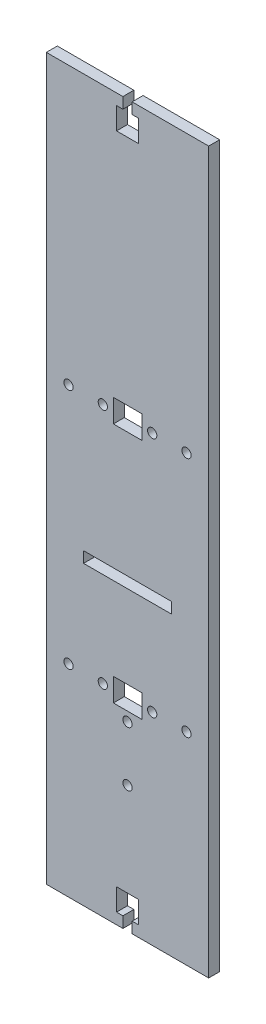
from build123d import *

# Parameters (mm, degrees)
SKETCH1_W           = 73.9
SKETCH1_H           = 328
BOSS_EXTRUDE1_DEPTH = 5
SKETCH2_R           = 2.1
CUT_EXTRUDE1_DEPTH  = 10
CUT_EXTRUDE2_DEPTH  = 10
SKETCH5_R           = 2.1
CUT_EXTRUDE3_DEPTH  = 5
SKETCH6_R           = 2.1
SKETCH6_W           = 13
SKETCH6_H           = 10.5
CUT_EXTRUDE4_DEPTH  = 180
SKETCH7_R           = 2.1
CUT_EXTRUDE5_DEPTH  = 180
SKETCH8_W           = 40
SKETCH8_H           = 5
CUT_EXTRUDE6_DEPTH  = 5


with BuildPart() as part:
    # Sketch1 → Boss-Extrude1 (new body)
    with BuildSketch(Plane.XY):
        Rectangle(SKETCH1_W, SKETCH1_H)
    extrude(amount=BOSS_EXTRUDE1_DEPTH)

    # Sketch2 → Cut-Extrude1 (cut)
    with BuildSketch(Plane.XY.offset(5)):
        with Locations((-0.000417228, -81.5)):
            Circle(SKETCH2_R)
    extrude(amount=-CUT_EXTRUDE1_DEPTH, mode=Mode.SUBTRACT)

    # Sketch3 → Cut-Extrude2 (cut)
    with BuildSketch(Plane.XY.offset(5)):
        Polygon((-2.1, -164), (-2.1, -159), (-5, -159), (-5, -149), (5, -149), (5, -159), (2.1, -159), (2.1, -164), align=None)
        Polygon((2.1, 164), (2.1, 159), (5, 159), (5, 149), (-5, 149), (-5, 159), (-2.1, 159), (-2.1, 164), align=None)
    extrude(amount=-CUT_EXTRUDE2_DEPTH, mode=Mode.SUBTRACT)

    # Sketch5 → Cut-Extrude3 (cut)
    with BuildSketch(Plane.XY.offset(5)):
        with Locations((-0.000417228, -106.5)):
            Circle(SKETCH5_R)
    extrude(amount=-CUT_EXTRUDE3_DEPTH, mode=Mode.SUBTRACT)

    # Sketch6 → Cut-Extrude4 (cut)
    with BuildSketch(Plane.XY.offset(5)):
        with Locations((-26.856574817, 38)):
            Circle(SKETCH6_R)
        with Locations((26.85574036, 38)):
            Circle(SKETCH6_R)
        with Locations((26.85574036, -72)):
            Circle(SKETCH6_R)
        with Locations((-26.856574817, -72)):
            Circle(SKETCH6_R)
        with Locations((0.059582772, 38)):
            Rectangle(SKETCH6_W, SKETCH6_H)
        with Locations((0.059582772, -72)):
            Rectangle(SKETCH6_W, SKETCH6_H)
    extrude(amount=-CUT_EXTRUDE4_DEPTH, mode=Mode.SUBTRACT)

    # Sketch7 → Cut-Extrude5 (cut)
    with BuildSketch(Plane(origin=(0, 0, 0), x_dir=(-1, 0, 0), z_dir=(0, 0, -1))):
        with Locations((11.250417228, 38)):
            Circle(SKETCH7_R)
        with Locations((-11.249582772, 38)):
            Circle(SKETCH7_R)
        with Locations((-11.249582772, -72)):
            Circle(SKETCH7_R)
        with Locations((11.250417228, -72)):
            Circle(SKETCH7_R)
    extrude(amount=-CUT_EXTRUDE5_DEPTH, mode=Mode.SUBTRACT)

    # Sketch8 → Cut-Extrude6 (cut)
    with BuildSketch(Plane.XY.offset(5)):
        with Locations((-0.000417229, -26.5)):
            Rectangle(SKETCH8_W, SKETCH8_H)
    extrude(amount=-CUT_EXTRUDE6_DEPTH, mode=Mode.SUBTRACT)


solid = part.part
